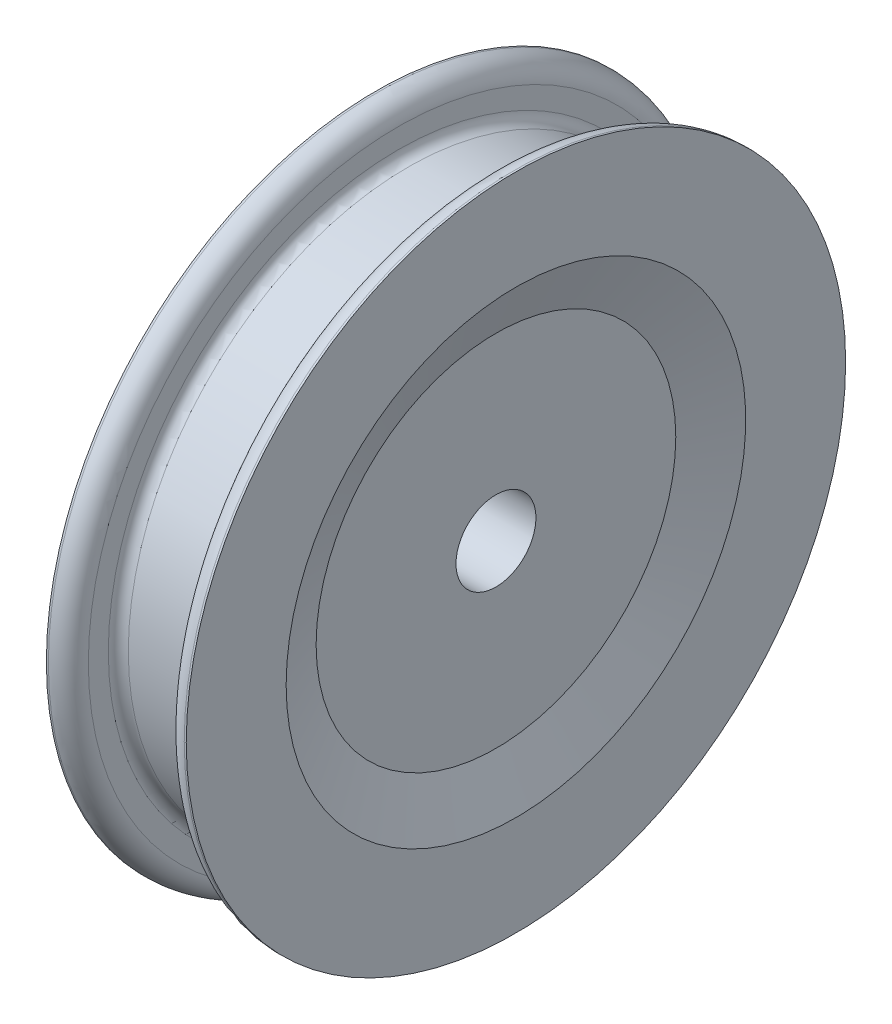
from build123d import *

# Parameters (mm, degrees)
FILLET1_R = 0.5


with BuildPart() as part:
    # Sketch1 → Revolve1 (revolve)
    with BuildSketch(Plane.XY):
        with BuildLine():
            Line((1.75, 8.25), (1.2, 8.25))
            Line((1.2, 8.25), (1.2, 7.25))
            ThreePointArc((1.2, 7.25), (1.126776695, 7.073223305), (0.95, 7))
            Line((0.95, 7), (-0.95, 7))
            ThreePointArc((-0.95, 7), (-1.126776695, 7.073223305), (-1.2, 7.25))
            Line((-1.2, 7.25), (-1.2, 8.25))
            Line((-1.2, 8.25), (-1.75, 8.25))
            Line((-1.75, 8.25), (-1.75, 1))
            Line((-1.75, 1), (1.25, 1))
            Line((1.25, 1), (1.25, 4.5))
            Line((1.25, 4.5), (1.75, 5.75))
            Line((1.75, 5.75), (1.75, 8.25))
        make_face()
    revolve(axis=Axis((0, 0, 0), (1, 0, 0)))

    # Fillet1
    fillet1_edges = [part.edges().sort_by_distance(p)[0] for p in [
        (1.2, -8.25, 0),
        (-1.2, -8.25, 0),
    ]]
    fillet(fillet1_edges, radius=FILLET1_R)


solid = part.part
